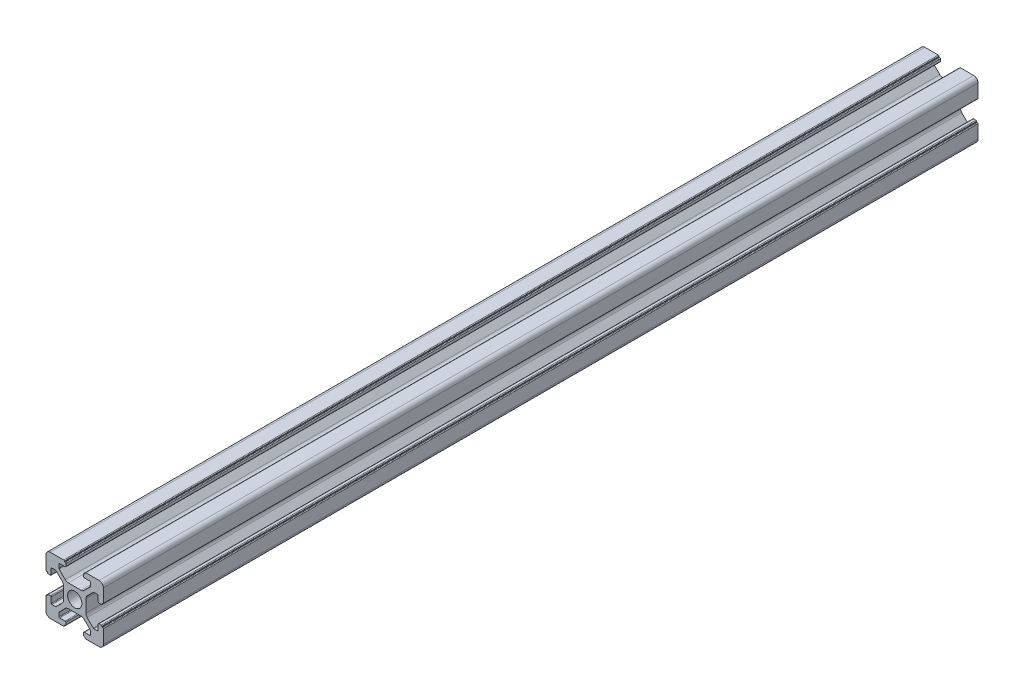
from build123d import *

# Parameters (mm, degrees)
SKETCH_1_R      = 2.5
EXTRUDE_1_DEPTH = 304.8


with BuildPart() as part:
    # 草图1 → 凸台-拉伸1 (new body)
    with BuildSketch(Plane.XY):
        with BuildLine():
            Line((-8.502261885, -10.002261885), (-3.85, -10.002261885))
            ThreePointArc((-3.85, -10.002261885), (-3.673223305, -9.929038581), (-3.6, -9.752261885))
            Line((-3.6, -9.752261885), (-3.6, -9.502261885))
            Line((-3.6, -9.502261885), (-3.35, -9.502261885))
            ThreePointArc((-3.35, -9.502261885), (-3.173223305, -9.429038581), (-3.1, -9.252261885))
            Line((-3.1, -9.252261885), (-3.1, -8.45))
            ThreePointArc((-3.1, -8.45), (-3.173223305, -8.273223305), (-3.35, -8.2))
            Line((-3.35, -8.2), (-5.25, -8.2))
            ThreePointArc((-5.25, -8.2), (-5.426776695, -8.126776695), (-5.5, -7.95))
            Line((-5.5, -7.95), (-5.5, -6.664213562))
            ThreePointArc((-5.5, -6.664213562), (-5.480969883, -6.568542704), (-5.426776695, -6.487436867))
            Line((-5.426776695, -6.487436867), (-3.278679656, -4.339339828))
            ThreePointArc((-3.278679656, -4.339339828), (-2.792044633, -4.014180701), (-2.218019485, -3.9))
            Line((-2.218019485, -3.9), (2.218019485, -3.9))
            ThreePointArc((2.218019485, -3.9), (2.792044633, -4.014180701), (3.278679656, -4.339339828))
            Line((3.278679656, -4.339339828), (5.426776695, -6.487436867))
            ThreePointArc((5.426776695, -6.487436867), (5.480969883, -6.568542704), (5.5, -6.664213562))
            Line((5.5, -6.664213562), (5.5, -7.95))
            ThreePointArc((5.5, -7.95), (5.426776695, -8.126776695), (5.25, -8.2))
            Line((5.25, -8.2), (3.35, -8.2))
            ThreePointArc((3.35, -8.2), (3.173223305, -8.273223305), (3.1, -8.45))
            Line((3.1, -8.45), (3.1, -9.252261885))
            ThreePointArc((3.1, -9.252261885), (3.173223305, -9.429038581), (3.35, -9.502261885))
            Line((3.35, -9.502261885), (3.6, -9.502261885))
            Line((3.6, -9.502261885), (3.6, -9.752261885))
            ThreePointArc((3.6, -9.752261885), (3.673223305, -9.929038581), (3.85, -10.002261885))
            Line((3.85, -10.002261885), (8.502261885, -10.002261885))
            ThreePointArc((8.502261885, -10.002261885), (9.562922057, -9.562922057), (10.002261885, -8.502261885))
            Line((10.002261885, -8.502261885), (10.002261885, -3.85))
            ThreePointArc((10.002261885, -3.85), (9.929038581, -3.673223305), (9.752261885, -3.6))
            Line((9.752261885, -3.6), (9.502261885, -3.6))
            Line((9.502261885, -3.6), (9.502261885, -3.35))
            ThreePointArc((9.502261885, -3.35), (9.429038581, -3.173223305), (9.252261885, -3.1))
            Line((9.252261885, -3.1), (8.45, -3.1))
            ThreePointArc((8.45, -3.1), (8.273223305, -3.173223305), (8.2, -3.35))
            Line((8.2, -3.35), (8.2, -5.25))
            ThreePointArc((8.2, -5.25), (8.126776695, -5.426776695), (7.95, -5.5))
            Line((7.95, -5.5), (6.664213562, -5.5))
            ThreePointArc((6.664213562, -5.5), (6.568542704, -5.480969883), (6.487436867, -5.426776695))
            Line((6.487436867, -5.426776695), (4.339339828, -3.278679656))
            ThreePointArc((4.339339828, -3.278679656), (4.014180701, -2.792044633), (3.9, -2.218019485))
            Line((3.9, -2.218019485), (3.9, 2.218019485))
            ThreePointArc((3.9, 2.218019485), (4.014180701, 2.792044633), (4.339339828, 3.278679656))
            Line((4.339339828, 3.278679656), (6.487436867, 5.426776695))
            ThreePointArc((6.487436867, 5.426776695), (6.568542704, 5.480969883), (6.664213562, 5.5))
            Line((6.664213562, 5.5), (7.95, 5.5))
            ThreePointArc((7.95, 5.5), (8.126776695, 5.426776695), (8.2, 5.25))
            Line((8.2, 5.25), (8.2, 3.35))
            ThreePointArc((8.2, 3.35), (8.273223305, 3.173223305), (8.45, 3.1))
            Line((8.45, 3.1), (9.252261885, 3.1))
            ThreePointArc((9.252261885, 3.1), (9.429038581, 3.173223305), (9.502261885, 3.35))
            Line((9.502261885, 3.35), (9.502261885, 3.6))
            Line((9.502261885, 3.6), (9.752261885, 3.6))
            ThreePointArc((9.752261885, 3.6), (9.929038581, 3.673223305), (10.002261885, 3.85))
            Line((10.002261885, 3.85), (10.002261885, 8.502261885))
            ThreePointArc((10.002261885, 8.502261885), (9.562922057, 9.562922057), (8.502261885, 10.002261885))
            Line((8.502261885, 10.002261885), (3.85, 10.002261885))
            ThreePointArc((3.85, 10.002261885), (3.673223305, 9.929038581), (3.6, 9.752261885))
            Line((3.6, 9.752261885), (3.6, 9.502261885))
            Line((3.6, 9.502261885), (3.35, 9.502261885))
            ThreePointArc((3.35, 9.502261885), (3.173223305, 9.429038581), (3.1, 9.252261885))
            Line((3.1, 9.252261885), (3.1, 8.45))
            ThreePointArc((3.1, 8.45), (3.173223305, 8.273223305), (3.35, 8.2))
            Line((3.35, 8.2), (5.25, 8.2))
            ThreePointArc((5.25, 8.2), (5.426776695, 8.126776695), (5.5, 7.95))
            Line((5.5, 7.95), (5.5, 6.664213562))
            ThreePointArc((5.5, 6.664213562), (5.480969883, 6.568542704), (5.426776695, 6.487436867))
            Line((5.426776695, 6.487436867), (3.278679656, 4.339339828))
            ThreePointArc((3.278679656, 4.339339828), (2.792044633, 4.014180701), (2.218019485, 3.9))
            Line((2.218019485, 3.9), (-2.218019485, 3.9))
            ThreePointArc((-2.218019485, 3.9), (-2.792044633, 4.014180701), (-3.278679656, 4.339339828))
            Line((-3.278679656, 4.339339828), (-5.426776695, 6.487436867))
            ThreePointArc((-5.426776695, 6.487436867), (-5.480969883, 6.568542704), (-5.5, 6.664213562))
            Line((-5.5, 6.664213562), (-5.5, 7.95))
            ThreePointArc((-5.5, 7.95), (-5.426776695, 8.126776695), (-5.25, 8.2))
            Line((-5.25, 8.2), (-3.35, 8.2))
            ThreePointArc((-3.35, 8.2), (-3.173223305, 8.273223305), (-3.1, 8.45))
            Line((-3.1, 8.45), (-3.1, 9.252261885))
            ThreePointArc((-3.1, 9.252261885), (-3.173223305, 9.429038581), (-3.35, 9.502261885))
            Line((-3.35, 9.502261885), (-3.6, 9.502261885))
            Line((-3.6, 9.502261885), (-3.6, 9.752261885))
            ThreePointArc((-3.6, 9.752261885), (-3.673223305, 9.929038581), (-3.85, 10.002261885))
            Line((-3.85, 10.002261885), (-8.502261885, 10.002261885))
            ThreePointArc((-8.502261885, 10.002261885), (-9.562922057, 9.562922057), (-10.002261885, 8.502261885))
            Line((-10.002261885, 8.502261885), (-10.002261885, 3.85))
            ThreePointArc((-10.002261885, 3.85), (-9.929038581, 3.673223305), (-9.752261885, 3.6))
            Line((-9.752261885, 3.6), (-9.502261885, 3.6))
            Line((-9.502261885, 3.6), (-9.502261885, 3.35))
            ThreePointArc((-9.502261885, 3.35), (-9.429038581, 3.173223305), (-9.252261885, 3.1))
            Line((-9.252261885, 3.1), (-8.45, 3.1))
            ThreePointArc((-8.45, 3.1), (-8.273223305, 3.173223305), (-8.2, 3.35))
            Line((-8.2, 3.35), (-8.2, 5.25))
            ThreePointArc((-8.2, 5.25), (-8.126776695, 5.426776695), (-7.95, 5.5))
            Line((-7.95, 5.5), (-6.664213562, 5.5))
            ThreePointArc((-6.664213562, 5.5), (-6.568542704, 5.480969883), (-6.487436867, 5.426776695))
            Line((-6.487436867, 5.426776695), (-4.339339828, 3.278679656))
            ThreePointArc((-4.339339828, 3.278679656), (-4.014180701, 2.792044633), (-3.9, 2.218019485))
            Line((-3.9, 2.218019485), (-3.9, -2.218019485))
            ThreePointArc((-3.9, -2.218019485), (-4.014180701, -2.792044633), (-4.339339828, -3.278679656))
            Line((-4.339339828, -3.278679656), (-6.487436867, -5.426776695))
            ThreePointArc((-6.487436867, -5.426776695), (-6.568542704, -5.480969883), (-6.664213562, -5.5))
            Line((-6.664213562, -5.5), (-7.95, -5.5))
            ThreePointArc((-7.95, -5.5), (-8.126776695, -5.426776695), (-8.2, -5.25))
            Line((-8.2, -5.25), (-8.2, -3.35))
            ThreePointArc((-8.2, -3.35), (-8.273223305, -3.173223305), (-8.45, -3.1))
            Line((-8.45, -3.1), (-9.252261885, -3.1))
            ThreePointArc((-9.252261885, -3.1), (-9.429038581, -3.173223305), (-9.502261885, -3.35))
            Line((-9.502261885, -3.35), (-9.502261885, -3.6))
            Line((-9.502261885, -3.6), (-9.752261885, -3.6))
            ThreePointArc((-9.752261885, -3.6), (-9.929038581, -3.673223305), (-10.002261885, -3.85))
            Line((-10.002261885, -3.85), (-10.002261885, -8.502261885))
            ThreePointArc((-10.002261885, -8.502261885), (-9.562922057, -9.562922057), (-8.502261885, -10.002261885))
        make_face()
        Circle(SKETCH_1_R, mode=Mode.SUBTRACT)
    extrude(amount=EXTRUDE_1_DEPTH)


solid = part.part
